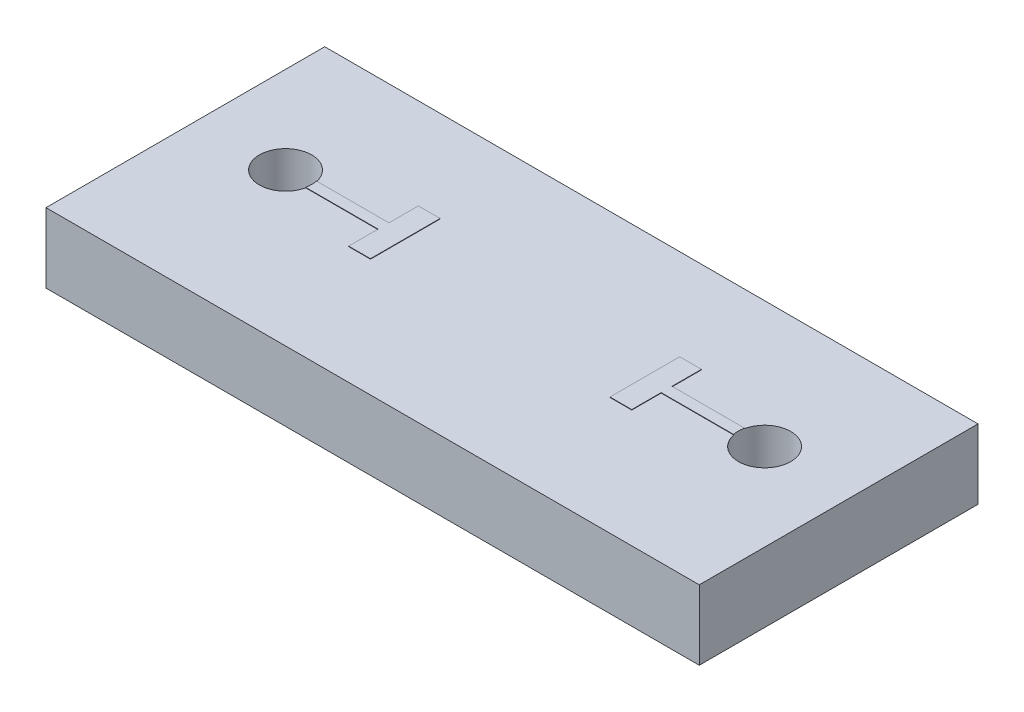
from build123d import *

# Parameters (mm, degrees)
SKETCH1_W           = 15
SKETCH1_H           = 4
BOSS_EXTRUDE1_DEPTH = 1.6
SKETCH3_R           = 0.6
CUT_EXTRUDE1_DEPTH  = 1.6
SKETCH2_W           = 0.5
SKETCH2_H           = 1.6
BOSS_EXTRUDE2_DEPTH = 0.01
BOSS_EXTRUDE3_DEPTH = 0.01
SKETCH5_W           = 15
SKETCH5_H           = 1.6
BOSS_EXTRUDE4_DEPTH = 1.5
SKETCH6_W           = 15
SKETCH6_H           = 1.6
BOSS_EXTRUDE5_DEPTH = 0.9


with BuildPart() as part:
    # Sketch1 → Boss-Extrude1 (new body)
    with BuildSketch(Plane(origin=(0, 0, 0), x_dir=(1, 0, 0), z_dir=(0, 1, 0))):
        Rectangle(SKETCH1_W, SKETCH1_H)
    extrude(amount=BOSS_EXTRUDE1_DEPTH)

    # Sketch3 → Cut-Extrude1 (cut)
    with BuildSketch(Plane(origin=(0, 1.6, 0), x_dir=(1, 0, 0), z_dir=(0, 1, 0))):
        with Locations((5.5, 0)):
            Circle(SKETCH3_R)
        with Locations((-5.5, 0)):
            Circle(SKETCH3_R)
    extrude(amount=-CUT_EXTRUDE1_DEPTH, mode=Mode.SUBTRACT)

    # Sketch2 → Boss-Extrude2 (add)
    with BuildSketch(Plane(origin=(0, 1.6, 0), x_dir=(1, 0, 0), z_dir=(0, 1, 0))):
        with Locations((-3, 0)):
            Rectangle(SKETCH2_W, SKETCH2_H)
        with Locations((3, 0)):
            Rectangle(SKETCH2_W, SKETCH2_H)
    extrude(amount=BOSS_EXTRUDE2_DEPTH)

    # Sketch4 → Boss-Extrude3 (add)
    with BuildSketch(Plane(origin=(0, 1.6, 0), x_dir=(1, 0, 0), z_dir=(0, 1, 0))):
        with BuildLine():
            Line((3.25, -0.125), (4.913165, -0.125))
            ThreePointArc((4.913165, -0.125), (4.9, 0), (4.913165, 0.125))
            Line((4.913165, 0.125), (3.25, 0.125))
            Line((3.25, 0.125), (3.25, -0.125))
        make_face()
        with BuildLine():
            Line((-3.25, 0.125), (-4.913165, 0.125))
            ThreePointArc((-4.913165, 0.125), (-4.9033, 0.062846), (-4.9, 0))
            ThreePointArc((-4.9, 0), (-4.9033, -0.062846), (-4.913165, -0.125))
            Line((-4.913165, -0.125), (-3.25, -0.125))
            Line((-3.25, -0.125), (-3.25, 0.125))
        make_face()
    extrude(amount=BOSS_EXTRUDE3_DEPTH)

    # Sketch5 → Boss-Extrude4 (add)
    with BuildSketch(Plane.XY.offset(2)):
        with Locations((0, 0.8)):
            Rectangle(SKETCH5_W, SKETCH5_H)
    extrude(amount=BOSS_EXTRUDE4_DEPTH)

    # Sketch6 → Boss-Extrude5 (add)
    with BuildSketch(Plane(origin=(0, 0, -2), x_dir=(-1, 0, 0), z_dir=(0, 0, -1))):
        with Locations((0, 0.8)):
            Rectangle(SKETCH6_W, SKETCH6_H)
    extrude(amount=BOSS_EXTRUDE5_DEPTH)


solid = part.part
